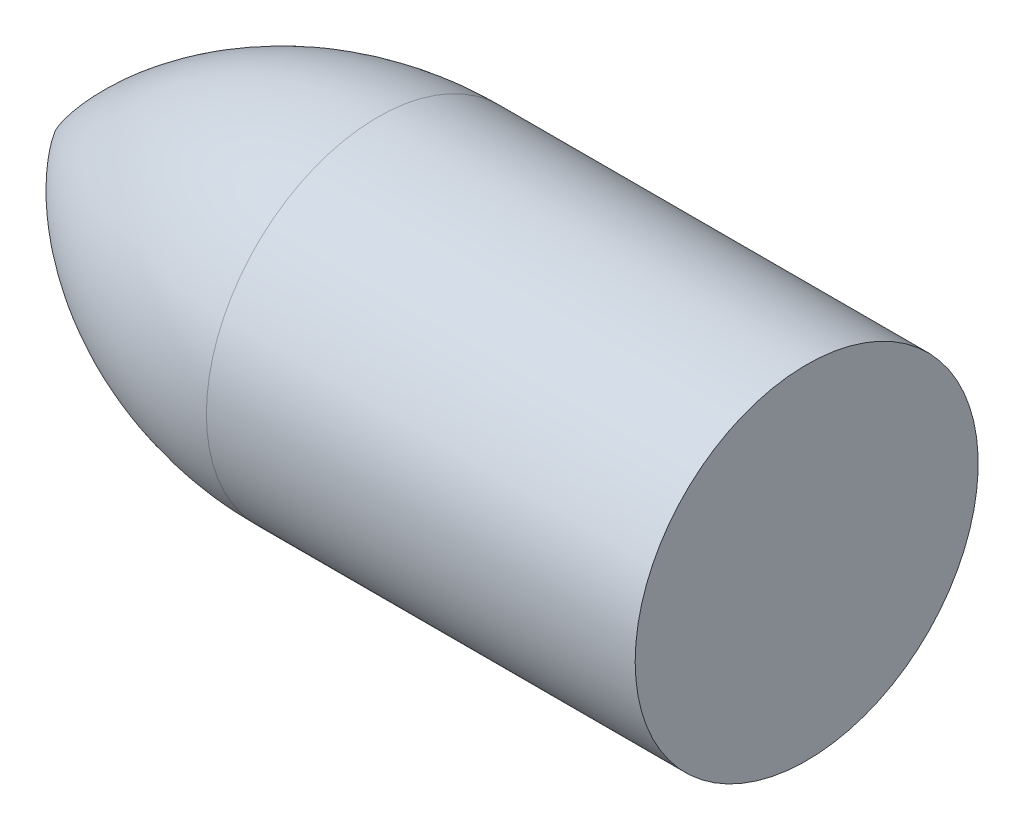
from build123d import *


with BuildPart() as part:
    # Sketch2 → Revolve1 (revolve)
    with BuildSketch(Plane.XY):
        with BuildLine():
            Line((0, 0), (350, 0))
            Line((350, 0), (350, 80))
            Line((350, 80), (150, 80))
            ThreePointArc((150, 80), (65, 58.75), (0, 0))
        make_face()
    revolve(axis=Axis((0, 0, 0), (1, 0, 0)))


solid = part.part
